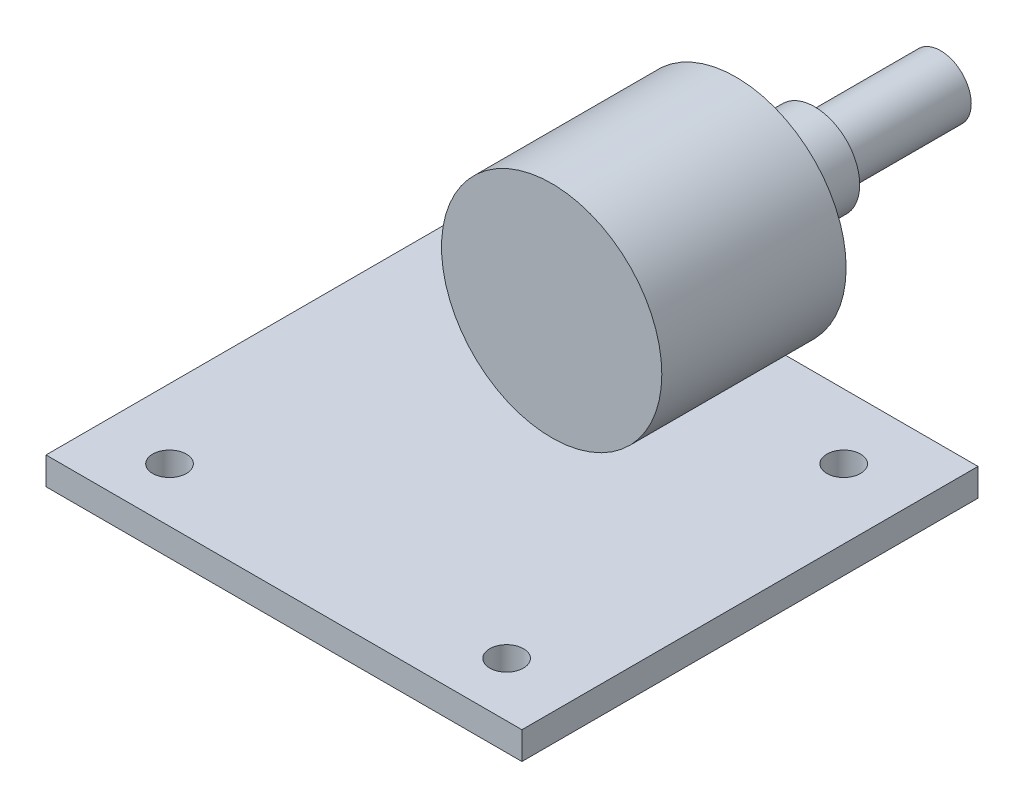
from build123d import *

# Parameters (mm, degrees)
CROQUIS2_W                            = 48
CROQUIS2_H                            = 2.78
SALIENTE_EXTRUIR1_DEPTH               = 19
CROQUIS2_3_W                          = 48
CROQUIS2_3_H                          = 2.78
SALIENTE_EXTRUIR2_DEPTH               = 27
CROQUIS5_W                            = 1.7
CROQUIS5_H                            = 2.78
TALADRO_DE_MARGEN_PARA_M31_AT_2_COUNT = 2
TALADRO_DE_MARGEN_PARA_M31_AT_2_PITCH = 34
TALADRO_DE_MARGEN_PARA_M31_AT_3_COUNT = 2
TALADRO_DE_MARGEN_PARA_M31_AT_3_PITCH = 48.083261121
TALADRO_DE_MARGEN_PARA_M31_AT_4_COUNT = 2
TALADRO_DE_MARGEN_PARA_M31_AT_4_PITCH = 34


with BuildPart() as part:
    # Croquis1 → Revolución1 (revolve)
    with BuildSketch(Plane(origin=(0, 0, 0), x_dir=(0, 0, -1), z_dir=(1, 0, 0))):
        Polygon((0, 0), (39.22, 0), (39.22, 3.1), (26.52, 3.1), (26.52, 4.55), (18.59, 4.55), (18.59, 11.11), (0, 11.11), align=None)
    revolve(axis=Axis((0, 0, 0), (0, 0, -1)))


with BuildPart() as body_2:
    # Croquis2 → Saliente-Extruir1 (new body)
    with BuildSketch(Plane.XY):
        with Locations((0, -12.5)):
            Rectangle(CROQUIS2_W, CROQUIS2_H)
    extrude(amount=-SALIENTE_EXTRUIR1_DEPTH)

    # Croquis2_3 → Saliente-Extruir2 (add)
    with BuildSketch(Plane.XY):
        with Locations((0, -12.5)):
            Rectangle(CROQUIS2_3_W, CROQUIS2_3_H)
    extrude(amount=SALIENTE_EXTRUIR2_DEPTH)

    # Croquis5 → Taladro de margen para M31 (revolve, cut)
    with BuildSketch(Plane(origin=(-17, -11.11, -12.458), x_dir=(0, 0, 1), z_dir=(1, 0, 0))):
        with Locations((0.85, 1.39)):
            Rectangle(CROQUIS5_W, CROQUIS5_H)
    taladro_de_margen_para_m31 = revolve(axis=Axis((-17, -4.76, -12.458), (0, -1, 0)), mode=Mode.SUBTRACT)

    # Taladro de margen para M31 at 2: Taladro de margen para M31 ×2
    with Locations(*[(0, 0, i * TALADRO_DE_MARGEN_PARA_M31_AT_2_PITCH) for i in range(1, TALADRO_DE_MARGEN_PARA_M31_AT_2_COUNT)]):
        add(taladro_de_margen_para_m31, mode=Mode.SUBTRACT)

    # Taladro de margen para M31 at 3: Taladro de margen para M31 ×2
    with Locations(*[Vector(0.7071067811865476, 0, 0.7071067811865476) * (i * TALADRO_DE_MARGEN_PARA_M31_AT_3_PITCH) for i in range(1, TALADRO_DE_MARGEN_PARA_M31_AT_3_COUNT)]):
        add(taladro_de_margen_para_m31, mode=Mode.SUBTRACT)

    # Taladro de margen para M31 at 4: Taladro de margen para M31 ×2
    with Locations(*[(i * TALADRO_DE_MARGEN_PARA_M31_AT_4_PITCH, 0, 0) for i in range(1, TALADRO_DE_MARGEN_PARA_M31_AT_4_COUNT)]):
        add(taladro_de_margen_para_m31, mode=Mode.SUBTRACT)


solid = Compound([part.part, body_2.part])
